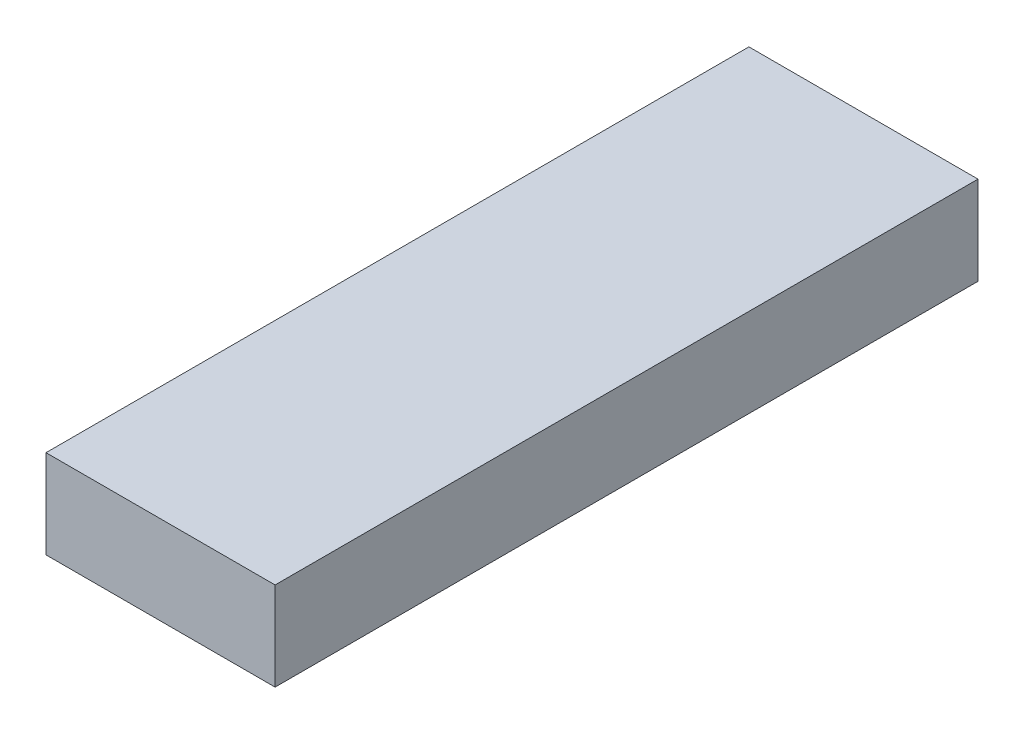
from build123d import *

# Parameters (mm, degrees)
SKETCH1_W           = 44
SKETCH1_H           = 135
BOSS_EXTRUDE1_DEPTH = 17


with BuildPart() as part:
    # Sketch1 → Boss-Extrude1 (new body)
    with BuildSketch(Plane(origin=(0, 0, 0), x_dir=(1, 0, 0), z_dir=(0, 1, 0))):
        with Locations((22, 67.5)):
            Rectangle(SKETCH1_W, SKETCH1_H)
    extrude(amount=BOSS_EXTRUDE1_DEPTH)


solid = part.part
